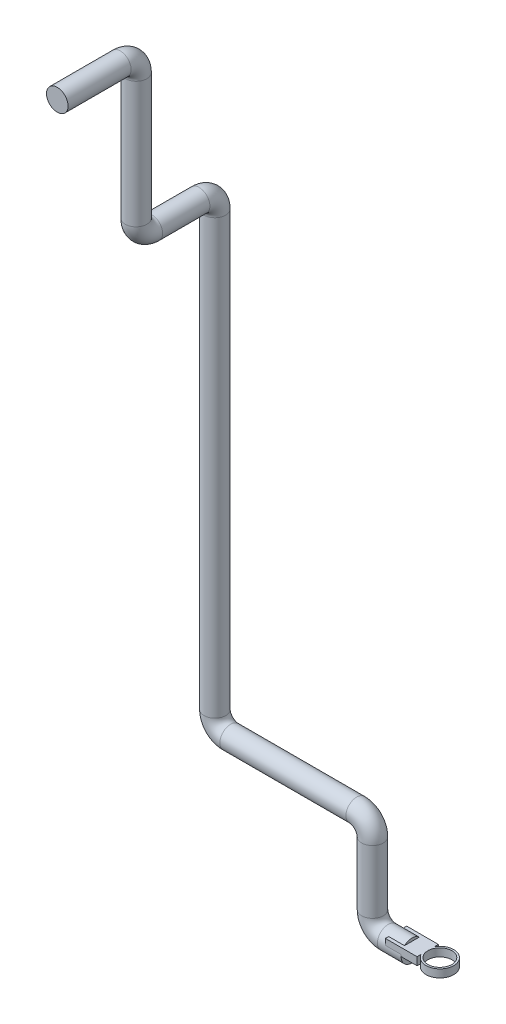
from build123d import *

# Parameters (mm, degrees)
CROQUIS1_R              = 13.7
CROQUIS2_R              = 17.598610065
CROQUIS2_R_2            = 15.183788675
SALIENTE_EXTRUIR1_DEPTH = 10
CROQUIS3_W              = 40.216102736
CROQUIS3_H              = 27.024768892
SALIENTE_EXTRUIR2_DEPTH = 10


with BuildPart() as part:
    # Barrer1: sweep along a curve in space
    with BuildLine() as barrer1_path:
        Line((0, 0, 0), (-30, 0, 0))
        ThreePointArc((-30, 0, 0), (-44.142135624, 5.857864376, 0), (-50, 20, 0))
        Line((-50, 20, 0), (-50, 100, 0))
        ThreePointArc((-50, 100, 0), (-55.857864376, 114.142135624, 0), (-70, 120, 0))
        Line((-70, 120, 0), (-230, 120, 0))
        ThreePointArc((-230, 120, 0), (-244.142135624, 125.857864376, 0), (-250, 140, 0))
        Line((-250, 140, 0), (-250, 689.98, 0))
        ThreePointArc((-250, 689.98, 0), (-250, 704.122135624, 5.857864376), (-250, 709.98, 20))
        Line((-250, 709.98, 20), (-250, 709.98, 80))
        ThreePointArc((-250, 709.98, 80), (-250, 715.837864376, 94.142135624), (-250, 729.98, 100))
        Line((-250, 729.98, 100), (-250, 889.98, 100))
        ThreePointArc((-250, 889.98, 100), (-250, 904.122135624, 105.857864376), (-250, 909.98, 120))
        Line((-250, 909.98, 120), (-250, 909.98, 200))
    # Croquis1 → Barrer1 (sweep)
    with BuildSketch(Plane(origin=(0, 0, 0), x_dir=(0, 0, -1), z_dir=(1, 0, 0))):
        Circle(CROQUIS1_R)
    sweep(path=barrer1_path.line)



with BuildPart() as body_2:
    # Croquis2 → Saliente-Extruir1 (new body)
    with BuildSketch(Plane(origin=(0, 0, 0), x_dir=(1, 0, 0), z_dir=(0, 1, 0))):
        with Locations((35.549795944, 0)):
            Circle(CROQUIS2_R)
        with Locations((35.549795944, 0)):
            Circle(CROQUIS2_R_2, mode=Mode.SUBTRACT)
    extrude(amount=SALIENTE_EXTRUIR1_DEPTH)


with BuildPart() as part_1:
    add(part.part)

    add(body_2.part)  # Saliente-Extruir2 merges body 2
    # Croquis3 → Saliente-Extruir2 (add)
    with BuildSketch(Plane(origin=(0, 0, 0), x_dir=(1, 0, 0), z_dir=(0, 1, 0))):
        Rectangle(CROQUIS3_W, CROQUIS3_H)
    extrude(amount=SALIENTE_EXTRUIR2_DEPTH)


solid = part_1.part
